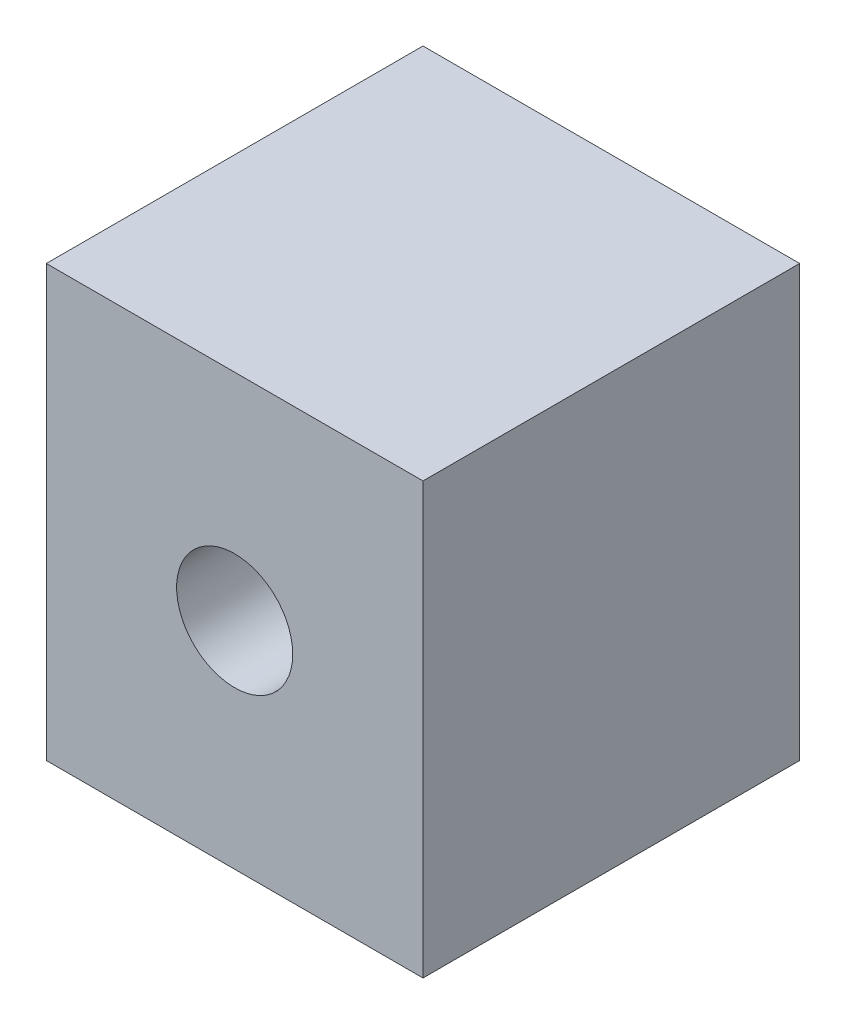
from build123d import *

# Parameters (mm, degrees)
SKETCH2_W           = 44.45
SKETCH2_H           = 44.45
BOSS_EXTRUDE1_DEPTH = 50.8
SKETCH3_R           = 6.849999
CUT_EXTRUDE1_DEPTH  = 50.8
SKETCH4_R           = 3.674999
CUT_EXTRUDE2_DEPTH  = 6.35


with BuildPart() as part:
    # Sketch2 → Boss-Extrude1 (new body)
    with BuildSketch(Plane(origin=(0, 0, 0), x_dir=(1, 0, 0), z_dir=(0, 1, 0))):
        with Locations((22.225, -22.225)):
            Rectangle(SKETCH2_W, SKETCH2_H)
    extrude(amount=BOSS_EXTRUDE1_DEPTH)

    # Sketch3 → Cut-Extrude1 (cut)
    with BuildSketch(Plane.XY.offset(44.45)):
        with Locations((22.225, 25.4)):
            Circle(SKETCH3_R)
    extrude(amount=-CUT_EXTRUDE1_DEPTH, mode=Mode.SUBTRACT)

    # Sketch4 → Cut-Extrude2 (cut)
    with BuildSketch(Plane.XZ):
        with Locations(Location((11.08184529, 22.225, 0), (0, 0, 270))):  # turned: the seam where the file's is
            Circle(SKETCH4_R)
        with Locations(Location((33.401, 22.225, 0), (0, 0, 270))):  # turned: the seam where the file's is
            Circle(SKETCH4_R)
    extrude(amount=-CUT_EXTRUDE2_DEPTH, mode=Mode.SUBTRACT)


solid = part.part
